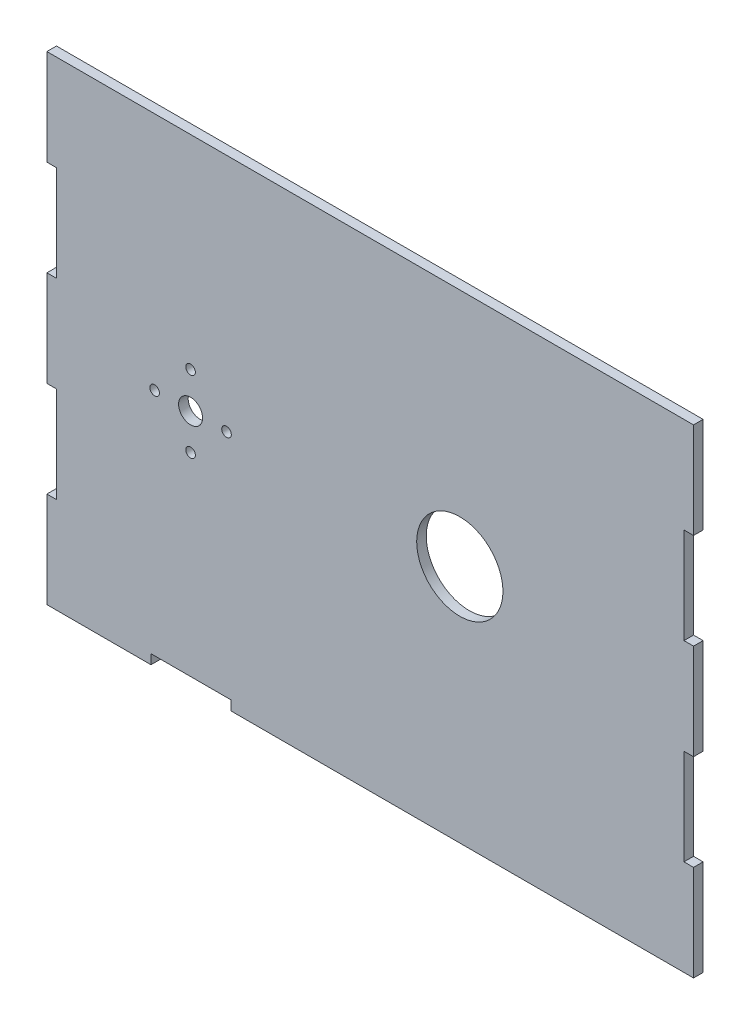
from build123d import *

# Parameters (mm, degrees)
SKETCH3_W           = 171.45
SKETCH3_H           = 127
BOSS_EXTRUDE1_DEPTH = 2.54
SKETCH4_W           = 2.54
SKETCH4_H           = 25.4
CUT_EXTRUDE1_DEPTH  = 3.54
LPATTERN1_COUNT     = 2
LPATTERN1_PITCH     = 50.8
SKETCH6_W           = 2.54
SKETCH6_H           = 25.4
CUT_EXTRUDE2_DEPTH  = 3.54
SKETCH7_W           = 2.54
SKETCH7_H           = 25.4
CUT_EXTRUDE3_DEPTH  = 3.54
SKETCH8_W           = 21.166666667
SKETCH8_H           = 2.54
CUT_EXTRUDE4_DEPTH  = 3.54
SKETCH9_R           = 11.43
CUT_EXTRUDE5_DEPTH  = 3.54
SKETCH10_R          = 3.175
CUT_EXTRUDE6_DEPTH  = 3.54
SKETCH11_R          = 1.27
CUT_EXTRUDE8_DEPTH  = 3.54
CIRPATTERN1_COUNT   = 4


with BuildPart() as part:
    # Sketch3 → Boss-Extrude1 (new body)
    with BuildSketch(Plane.XY):
        with Locations((85.725, 63.5)):
            Rectangle(SKETCH3_W, SKETCH3_H)
    extrude(amount=BOSS_EXTRUDE1_DEPTH)

    # Sketch4 → Cut-Extrude1 (cut, through all)
    with BuildSketch(Plane.XY.offset(2.54)):
        with Locations((1.27, 88.9)):
            Rectangle(SKETCH4_W, SKETCH4_H)
    cut_extrude1 = extrude(amount=-CUT_EXTRUDE1_DEPTH, mode=Mode.SUBTRACT)

    # LPattern1: Cut-Extrude1 ×2
    with Locations(*[(0, -i * LPATTERN1_PITCH, 0) for i in range(1, LPATTERN1_COUNT)]):
        add(cut_extrude1, mode=Mode.SUBTRACT)

    # Sketch6 → Cut-Extrude2 (cut, through all)
    with BuildSketch(Plane.XY.offset(2.54)):
        with Locations((170.18, 88.9)):
            Rectangle(SKETCH6_W, SKETCH6_H)
    extrude(amount=-CUT_EXTRUDE2_DEPTH, mode=Mode.SUBTRACT)

    # Sketch7 → Cut-Extrude3 (cut, through all)
    with BuildSketch(Plane.XY.offset(2.54)):
        with Locations((170.18, 38.1)):
            Rectangle(SKETCH7_W, SKETCH7_H)
    extrude(amount=-CUT_EXTRUDE3_DEPTH, mode=Mode.SUBTRACT)

    # Sketch8 → Cut-Extrude4 (cut, through all)
    with BuildSketch(Plane(origin=(0, 0, 0), x_dir=(-1, 0, 0), z_dir=(0, 0, -1))):
        with Locations((-38.184666667, 1.27)):
            Rectangle(SKETCH8_W, SKETCH8_H)
    extrude(amount=-CUT_EXTRUDE4_DEPTH, mode=Mode.SUBTRACT)

    # Sketch9 → Cut-Extrude5 (cut, through all)
    with BuildSketch(Plane(origin=(0, 0, 0), x_dir=(-1, 0, 0), z_dir=(0, 0, -1))):
        with Locations((-109.474, 63.5)):
            Circle(SKETCH9_R)
    extrude(amount=-CUT_EXTRUDE5_DEPTH, mode=Mode.SUBTRACT)

    # Sketch10 → Cut-Extrude6 (cut, through all)
    with BuildSketch(Plane(origin=(0, 0, 0), x_dir=(-1, 0, 0), z_dir=(0, 0, -1))):
        with Locations((-38.1, 63.5)):
            Circle(SKETCH10_R)
    extrude(amount=-CUT_EXTRUDE6_DEPTH, mode=Mode.SUBTRACT)

    # Sketch11 → Cut-Extrude8 (cut, through all)
    with BuildSketch(Plane(origin=(0, 0, 0), x_dir=(-1, 0, 0), z_dir=(0, 0, -1))):
        with Locations((-38.1, 73.025)):
            Circle(SKETCH11_R)
    cut_extrude8 = extrude(amount=-CUT_EXTRUDE8_DEPTH, mode=Mode.SUBTRACT)

    # CirPattern1: Cut-Extrude8 ×4 about axis
    cirpattern1_axis = Axis((38.1, 63.5, 0), (0, 0, 1))
    for i in range(1, CIRPATTERN1_COUNT):
        add(cut_extrude8.rotate(cirpattern1_axis, i * 360 / CIRPATTERN1_COUNT), mode=Mode.SUBTRACT)


solid = part.part
